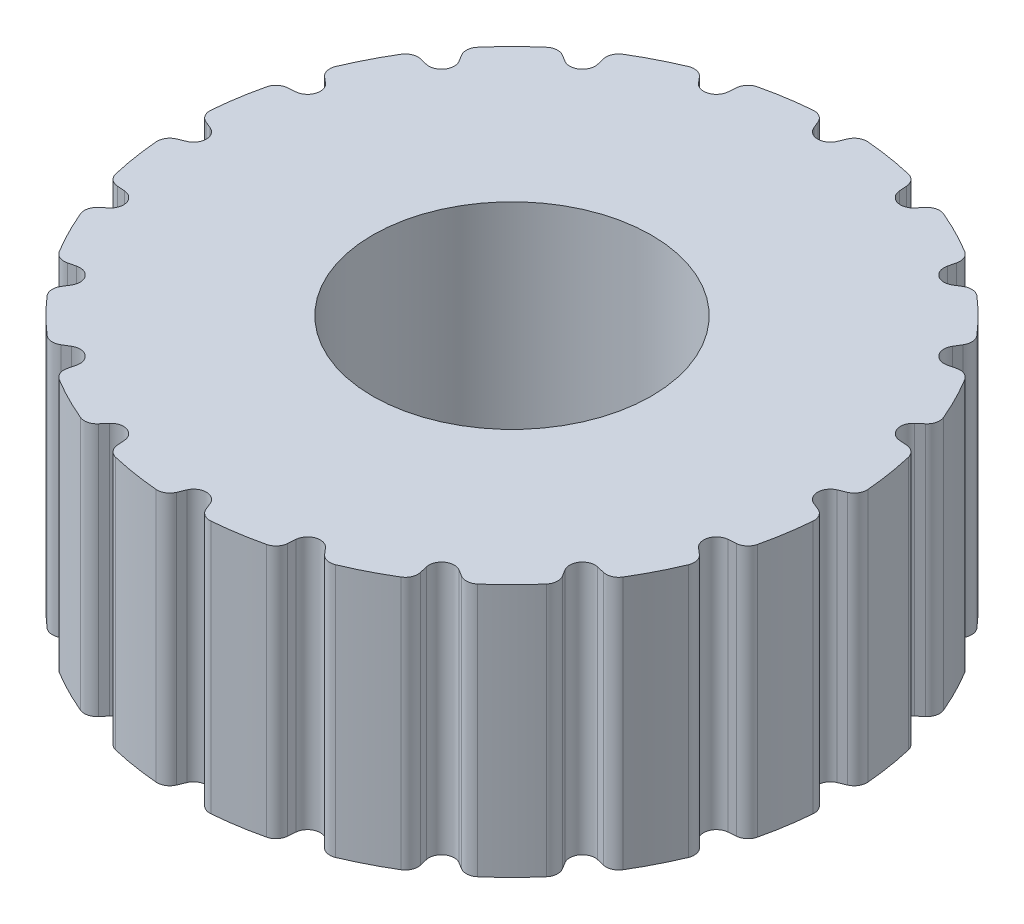
from build123d import *

# Parameters (mm, degrees)
SKETCH1_R                = 2.6
SKETCH1_R_2              = 1.1
BOSS_EXTRUDE1_DEPTH      = 2
CUT_EXTRUDE1_DEPTH       = 3
FILLET2_R                = 0.1
CIRPATTERN1_COUNT        = 20
FILLET2_OF_CIRPATTERN1_R = 0.1


with BuildPart() as part:
    # Sketch1 → Boss-Extrude1 (new body)
    with BuildSketch(Plane(origin=(0, 0, 0), x_dir=(1, 0, 0), z_dir=(0, 1, 0))):
        Circle(SKETCH1_R)
        Circle(SKETCH1_R_2, mode=Mode.SUBTRACT)
    extrude(amount=BOSS_EXTRUDE1_DEPTH)

    # Sketch2 → Cut-Extrude1 (cut, through all)
    with BuildSketch(Plane(origin=(0, 0, 0), x_dir=(1, 0, 0), z_dir=(0, 1, 0))):
        Polygon((-0.144974747, 2.6), (0, 2.25), (0.144974747, 2.6), align=None)
    cut_extrude1 = extrude(amount=CUT_EXTRUDE1_DEPTH, mode=Mode.SUBTRACT)

    # Fillet2
    fillet2_edges = [part.edges().sort_by_distance(p)[0] for p in [
        (0.143336922, 1, -2.596045941),
        (-0.143336922, 1, -2.596045941),
        (0, 1, -2.25),
    ]]
    fillet(fillet2_edges, radius=FILLET2_R)

    # CirPattern1: Cut-Extrude1 ×20 about axis
    cirpattern1_axis = Axis((0, 0, 0), (0, 1, 0))
    for i in range(1, CIRPATTERN1_COUNT):
        add(cut_extrude1.rotate(cirpattern1_axis, i * 360 / CIRPATTERN1_COUNT), mode=Mode.SUBTRACT)

    # Fillet2 of CirPattern1
    fillet2_of_cirpattern1_edges = [part.edges().sort_by_distance(p)[0] for p in [
        (-0.6659008, 1, -2.513279953),
        (-0.938543827, 1, -2.424692864),
        (-0.695288237, 1, -2.139877162),
        (-1.409955513, 1, -2.184496613),
        (-1.641879524, 1, -2.015993956),
        (-1.322516818, 1, -1.820288237),
        (-2.015993956, 1, -1.641879524),
        (-2.184496613, 1, -1.409955513),
        (-1.820288237, 1, -1.322516818),
        (-2.424692864, 1, -0.938543827),
        (-2.513279953, 1, -0.6659008),
        (-2.139877162, 1, -0.695288237),
        (-2.596045941, 1, -0.143336922),
        (-2.596045941, 1, 0.143336922),
        (-2.25, 1, 0),
        (-2.513279953, 1, 0.6659008),
        (-2.424692864, 1, 0.938543827),
        (-2.139877162, 1, 0.695288237),
        (-2.184496613, 1, 1.409955513),
        (-2.015993956, 1, 1.641879524),
        (-1.820288237, 1, 1.322516818),
        (-1.641879524, 1, 2.015993956),
        (-1.409955513, 1, 2.184496613),
        (-1.322516818, 1, 1.820288237),
        (-0.938543827, 1, 2.424692864),
        (-0.6659008, 1, 2.513279953),
        (-0.695288237, 1, 2.139877162),
        (-0.143336922, 1, 2.596045941),
        (0.143336922, 1, 2.596045941),
        (0, 1, 2.25),
        (0.6659008, 1, 2.513279953),
        (0.938543827, 1, 2.424692864),
        (0.695288237, 1, 2.139877162),
        (1.409955513, 1, 2.184496613),
        (1.641879524, 1, 2.015993956),
        (1.322516818, 1, 1.820288237),
        (2.015993956, 1, 1.641879524),
        (2.184496613, 1, 1.409955513),
        (1.820288237, 1, 1.322516818),
        (2.424692864, 1, 0.938543827),
        (2.513279953, 1, 0.6659008),
        (2.139877162, 1, 0.695288237),
        (2.596045941, 1, 0.143336922),
        (2.596045941, 1, -0.143336922),
        (2.25, 1, 0),
        (2.513279953, 1, -0.6659008),
        (2.424692864, 1, -0.938543827),
        (2.139877162, 1, -0.695288237),
        (2.184496613, 1, -1.409955513),
        (2.015993956, 1, -1.641879524),
        (1.820288237, 1, -1.322516818),
        (1.641879524, 1, -2.015993956),
        (1.409955513, 1, -2.184496613),
        (1.322516818, 1, -1.820288237),
        (0.938543827, 1, -2.424692864),
        (0.6659008, 1, -2.513279953),
        (0.695288237, 1, -2.139877162),
    ]]
    fillet(fillet2_of_cirpattern1_edges, radius=FILLET2_OF_CIRPATTERN1_R)


solid = part.part
